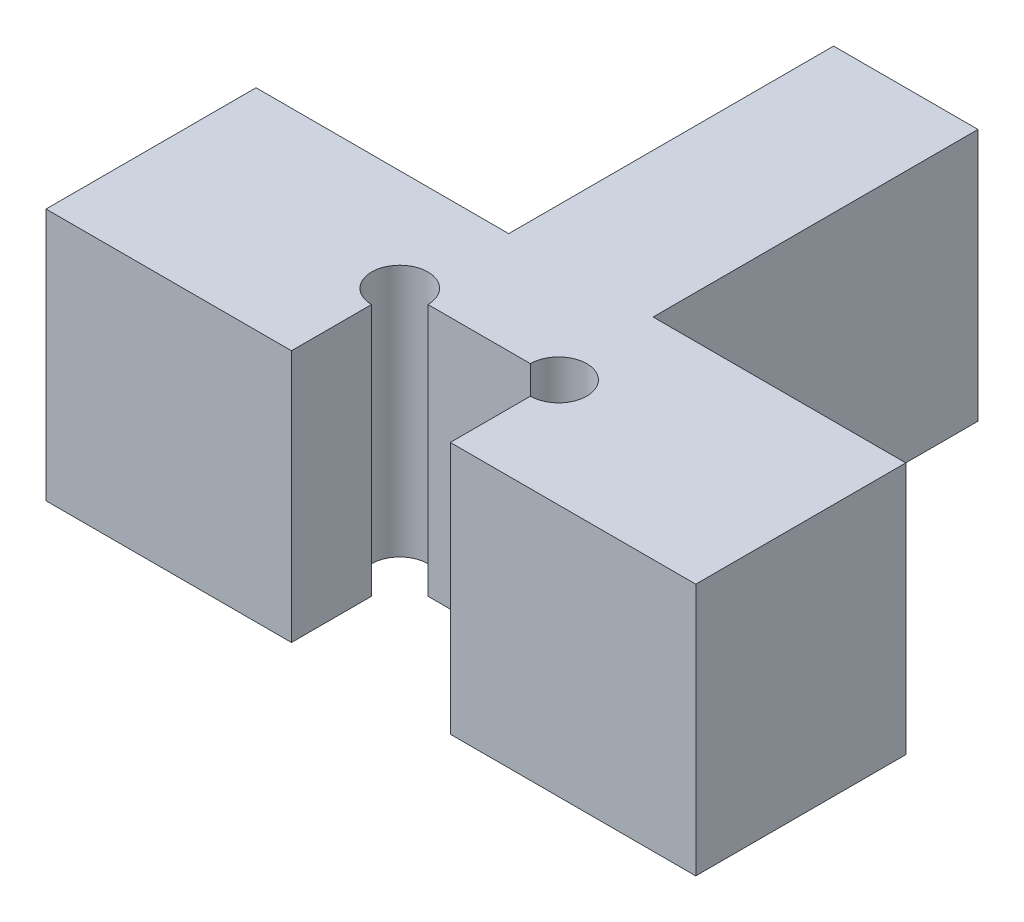
from build123d import *

# Parameters (mm, degrees)
BOSS_EXTRUDE1_DEPTH = 3.5


with BuildPart() as part:
    # Sketch1 → Boss-Extrude1 (new body)
    with BuildSketch(Plane(origin=(0, 0, 0), x_dir=(1, 0, 0), z_dir=(0, 1, 0))):
        with BuildLine():
            Line((-4.5, -0.16424544), (-1.1, -0.16424544))
            Line((-1.1, -0.16424544), (-1.1, 0.945359747))
            ThreePointArc((-1.1, 0.945359747), (-1.37605082, 1.61180538), (-0.709605187, 1.33575456))
            Line((-0.709605187, 1.33575456), (0.709605187, 1.33575456))
            ThreePointArc((0.709605187, 1.33575456), (1.37605082, 1.61180538), (1.1, 0.945359747))
            Line((1.1, 0.945359747), (1.1, -0.16424544))
            Line((1.1, -0.16424544), (4.5, -0.16424544))
            Line((4.5, -0.16424544), (4.5, 2.74500456))
            Line((4.5, 2.74500456), (1, 2.74500456))
            Line((1, 2.74500456), (1, 7.24500456))
            Line((1, 7.24500456), (-1, 7.24500456))
            Line((-1, 7.24500456), (-1, 2.74500456))
            Line((-1, 2.74500456), (-4.5, 2.74500456))
            Line((-4.5, 2.74500456), (-4.5, -0.16424544))
        make_face()
    extrude(amount=BOSS_EXTRUDE1_DEPTH)


solid = part.part
